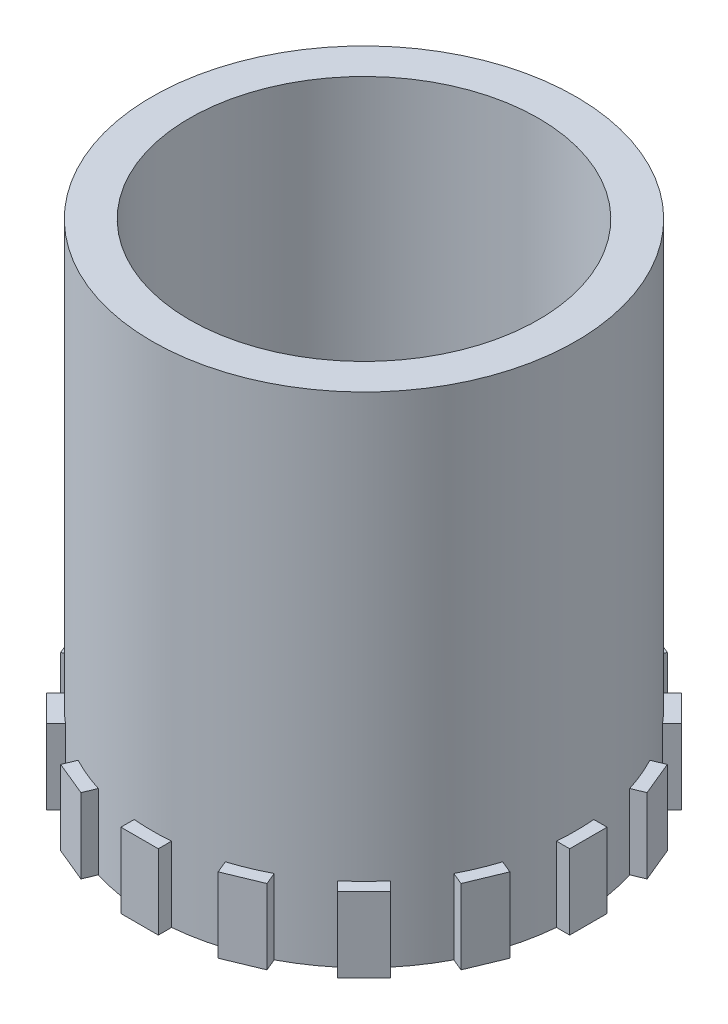
from build123d import *

# Parameters (mm, degrees)
SKETCH_1_R               = 17
SKETCH_1_R_2             = 14
EXTRUDE_1_DEPTH          = 40
SKETCH_2_W               = 3
SKETCH_2_H               = 2
EXTRUDE_2_DEPTH          = 6
PATTERN_CIRCULAR_1_COUNT = 16


with BuildPart() as part:
    # 草图1 → 凸台-拉伸1 (new body)
    with BuildSketch(Plane(origin=(0, 0, 0), x_dir=(1, 0, 0), z_dir=(0, 1, 0))):
        Circle(SKETCH_1_R)
        Circle(SKETCH_1_R_2, mode=Mode.SUBTRACT)
    extrude(amount=EXTRUDE_1_DEPTH)

    # 草图2 → 凸台-拉伸2 (add)
    with BuildSketch(Plane(origin=(0, 0, 0), x_dir=(-1, 0, 0), z_dir=(0, -1, 0))):
        with Locations((0, 17)):
            Rectangle(SKETCH_2_W, SKETCH_2_H)
    extrude_2 = extrude(amount=-EXTRUDE_2_DEPTH)

    # 阵列(圆周)1: 凸台-拉伸2 ×16 about axis
    pattern_circular_1_axis = Axis((0, 0, 0), (0, 1, 0))
    for i in range(1, PATTERN_CIRCULAR_1_COUNT):
        add(extrude_2.rotate(pattern_circular_1_axis, i * 360 / PATTERN_CIRCULAR_1_COUNT))


solid = part.part
